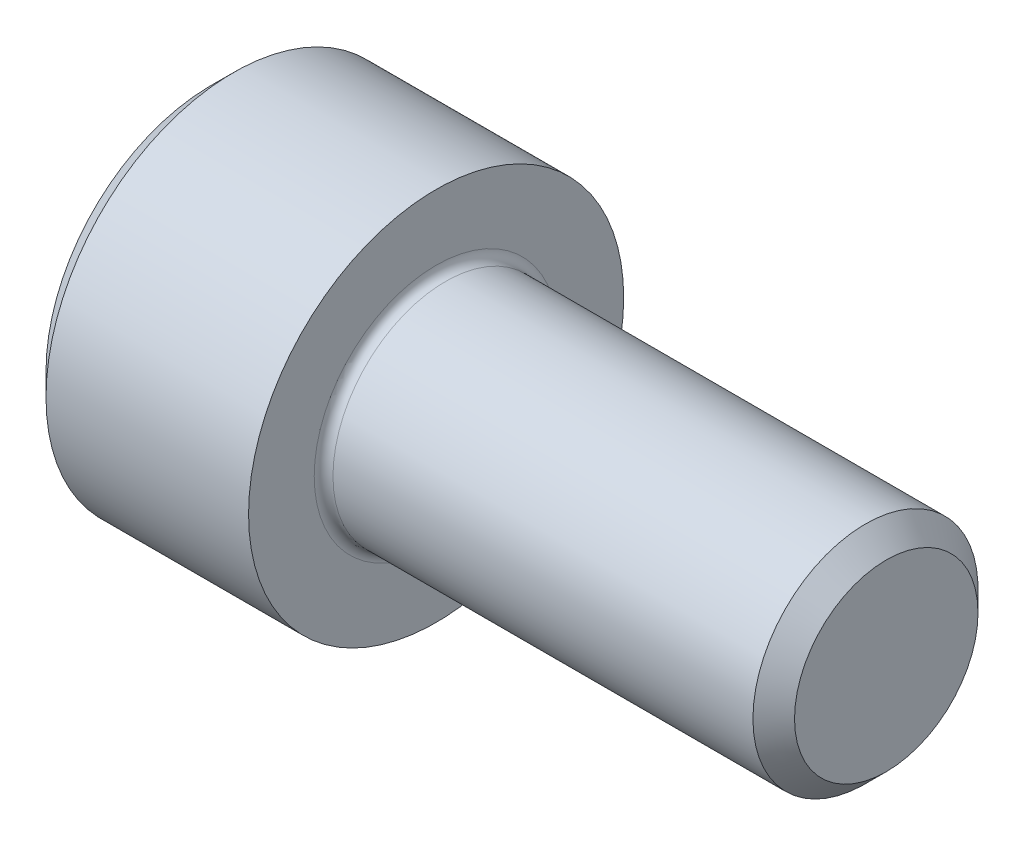
from build123d import *

# Parameters (mm, degrees)
FILLET1_R   = 0.25
HEX_2_DEPTH = 3


with BuildPart() as part:
    # BodySke → Base-Revolve (revolve)
    with BuildSketch(Plane.XY):
        Polygon((0, 0), (0, 4.4), (0.6, 5), (6, 5), (6, 3), (17.4455, 3), (18, 2.4455), (18, 0), align=None)
    revolve(axis=Axis((-31.75, 0, 0), (1, 0, 0)))

    # Fillet1
    fillet1_edges = [part.edges().sort_by_distance(p)[0] for p in [
        (6, -3, 0),
    ]]
    fillet(fillet1_edges, radius=FILLET1_R)

    # Sketch2 → Hex-PreBroach (revolve, cut)
    with BuildSketch(Plane.XY):
        Polygon((0, 2.542), (3, 2.542), (4.467624384, 0), (0, 0), align=None)
    revolve(axis=Axis((0, 0, 0), (1, 0, 0)), mode=Mode.SUBTRACT)

    # Sketch3 → Hex 2 (cut)
    with BuildSketch(Plane(origin=(0, 0, 0), x_dir=(0, 0.5, 0.866025404), z_dir=(-1, 0, 0))):
        Polygon((1.467624384, 2.542), (-1.467624384, 2.542), (-2.935248769, 0), (-1.467624384, -2.542), (1.467624384, -2.542), (2.935248769, 0), align=None)
    extrude(amount=-HEX_2_DEPTH, mode=Mode.SUBTRACT)


solid = part.part
